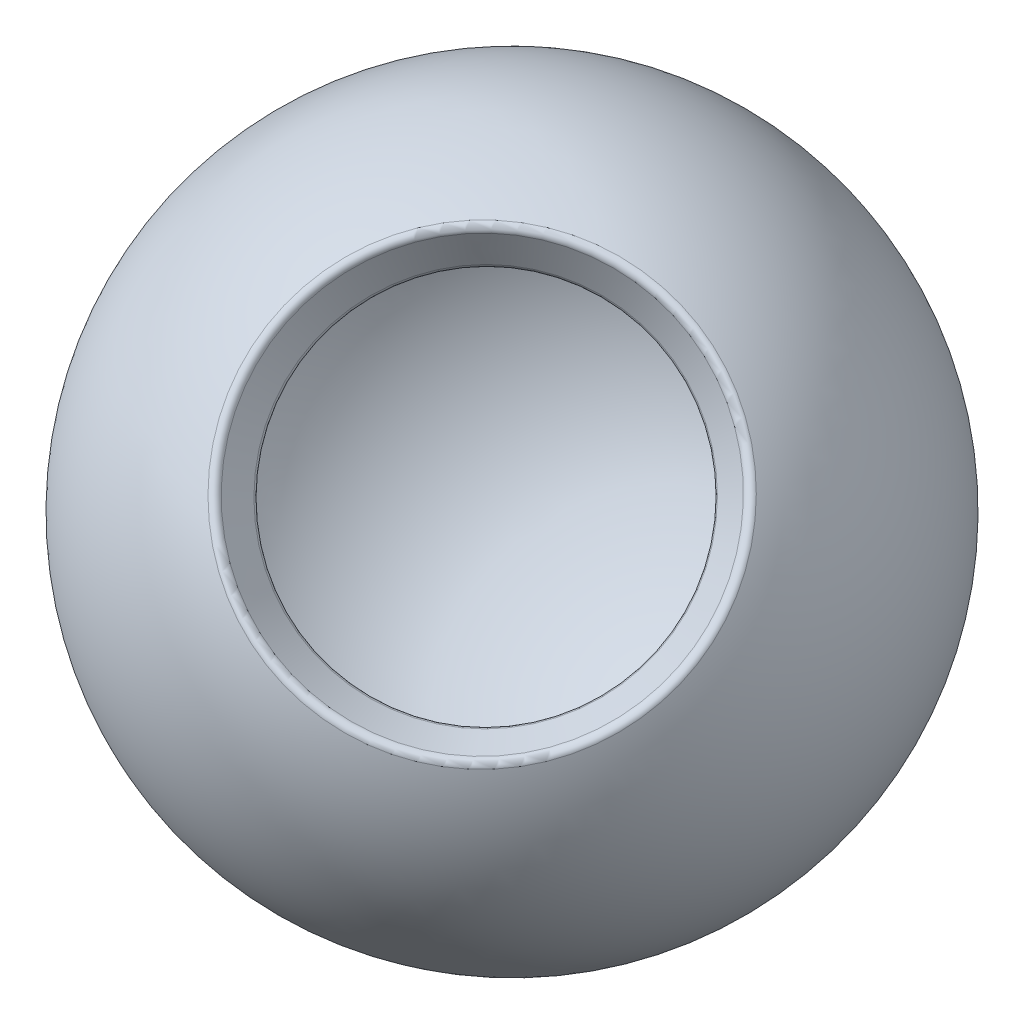
from build123d import *

# Parameters (mm, degrees)
FILLET1_R             = 2.54
BODY_MOVE_COPY1_ANGLE = 53.647435276


with BuildPart() as part:
    # Sketch1 → Revolve5 (revolve)
    with BuildSketch(Plane(origin=(0, 0, 0), x_dir=(0, 0, -1), z_dir=(1, 0, 0))):
        with BuildLine():
            Line((-72.844207417, 103.278008147), (-61.917576304, 87.673161704))
            ThreePointArc((-61.917576304, 87.673161704), (-102.953744833, -33.215492534), (0, -108.704301477))
            Line((0, -108.704301477), (0, -127.754301477))
            ThreePointArc((0, -127.754301477), (-121.122052745, -38.943938014), (-72.844207417, 103.278008147))
        make_face()
    revolve(axis=Axis((0, 75.583831792, 0), (0, -1, 0)))

    # Fillet1
    fillet1_edges = [part.edges().sort_by_distance(p)[0] for p in [
        (0, 103.278008147, -72.844207417),
        (0, 87.673161704, -61.917576304),
    ]]
    fillet(fillet1_edges, radius=FILLET1_R)


with BuildPart() as part_1:
    # Body-Move/Copy1: moved
    add(part.part.moved(Location((0, 0, 0))).rotate(Axis((2.292010946, -12.133386001, -1.482671109), (0.819160725, 0.219493455, -0.529904076)), BODY_MOVE_COPY1_ANGLE))


solid = part_1.part
